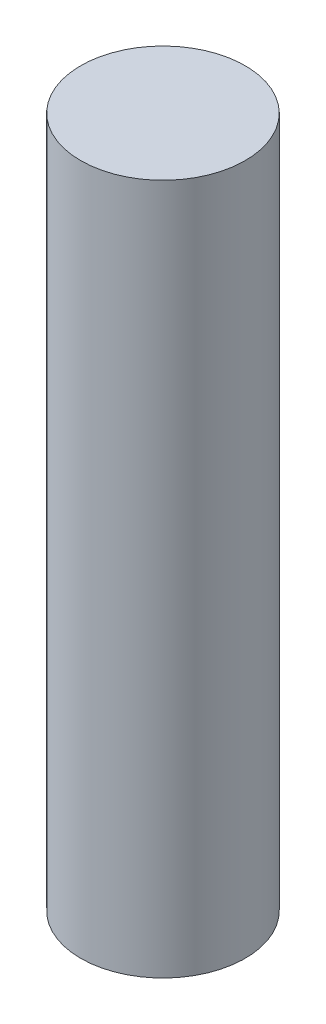
from build123d import *

# Parameters (mm, degrees)
SKETCH1_R           = 1.25
BOSS_EXTRUDE1_DEPTH = 10.5


with BuildPart() as part:
    # Sketch1 → Boss-Extrude1 (new body)
    with BuildSketch(Plane(origin=(0, 0, 0), x_dir=(1, 0, 0), z_dir=(0, 1, 0))):
        Circle(SKETCH1_R)
    extrude(amount=BOSS_EXTRUDE1_DEPTH)


solid = part.part
